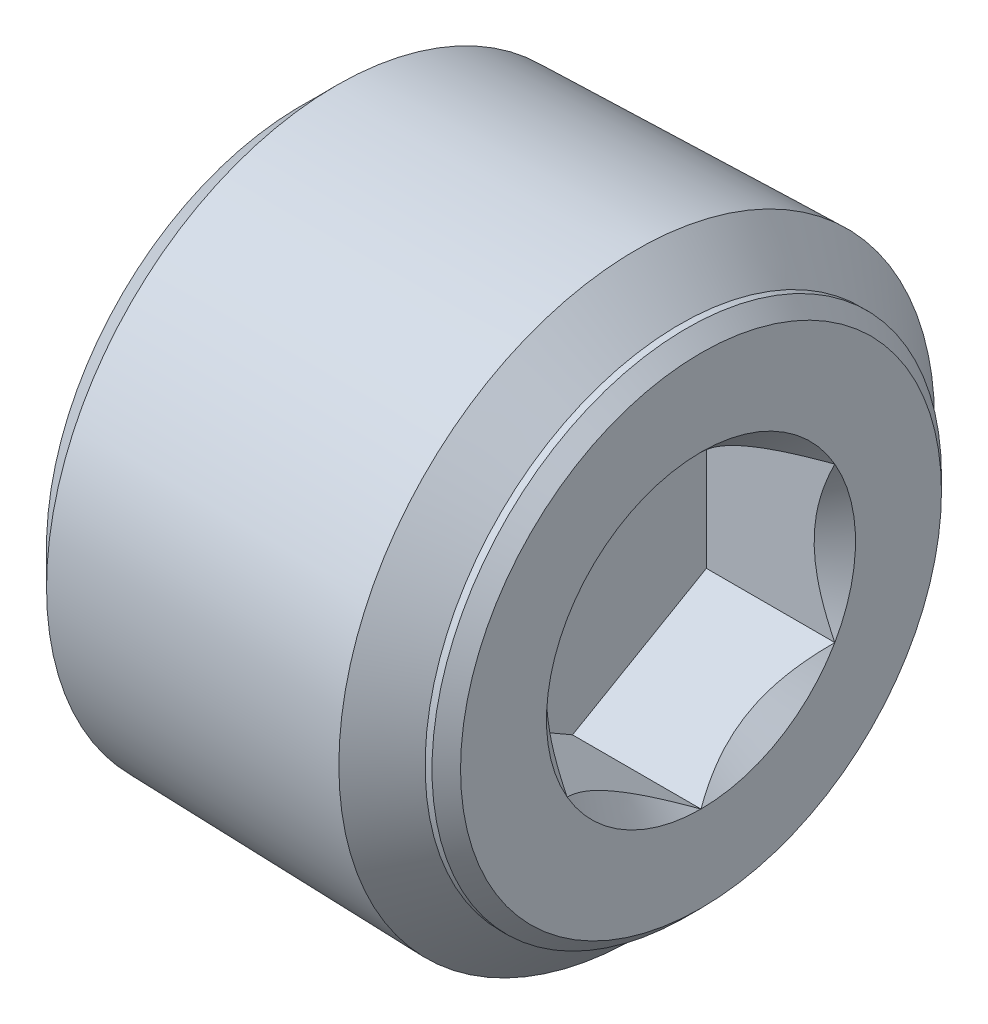
from build123d import *

# Parameters (mm, degrees)
SKETCH2_R          = 5.1435
EXTRUDE1_DEPTH     = 7.112
EXTRUDE1_TAPER     = -1.5
SKETCH5_OUTSIDE_W  = 32.218
SKETCH5_OUTSIDE_H  = 32.218
SKETCH5_OUTSIDE_R  = 4.532470965
CUT_EXTRUDE1_DEPTH = 8.1120001
CUT_EXTRUDE1_TAPER = 45
SKETCH9_OUTSIDE_W  = 15.994
SKETCH9_OUTSIDE_H  = 15.994
SKETCH9_OUTSIDE_R  = 4.532470965
CUT_EXTRUDE5_DEPTH = 0.376296296
SKETCH10_OUTSIDE_W = 31.44
SKETCH10_OUTSIDE_H = 31.44
SKETCH10_OUTSIDE_R = 4.532470965
CUT_EXTRUDE6_DEPTH = 7.735703804
CUT_EXTRUDE6_TAPER = 45
CUT_EXTRUDE7_DEPTH = 2.286
CHAMFER1_SIZE      = 0.254
SKETCH11_R         = 2.749630657
CUT_EXTRUDE8_DEPTH = 2.286
CUT_EXTRUDE8_TAPER = 45


with BuildPart() as part:
    # Sketch2 → Extrude1 (new body)
    with BuildSketch(Plane(origin=(-3.556, 0, 0), x_dir=(0, 0, -1), z_dir=(1, 0, 0))):
        Circle(SKETCH2_R)
    extrude(amount=EXTRUDE1_DEPTH, taper=EXTRUDE1_TAPER)

    # Sketch5 outside → Cut-Extrude1 (cut, through all)
    with BuildSketch(Plane(origin=(-3.556, 0, 0), x_dir=(0, 0, -1), z_dir=(1, 0, 0))):
        Rectangle(SKETCH5_OUTSIDE_W, SKETCH5_OUTSIDE_H)
        Circle(SKETCH5_OUTSIDE_R, mode=Mode.SUBTRACT)
    extrude(amount=CUT_EXTRUDE1_DEPTH, taper=CUT_EXTRUDE1_TAPER, mode=Mode.SUBTRACT)

    # Sketch9 outside → Cut-Extrude5 (cut)
    with BuildSketch(Plane(origin=(3.556, 0, 0), x_dir=(0, 0, -1), z_dir=(1, 0, 0))):
        Rectangle(SKETCH9_OUTSIDE_W, SKETCH9_OUTSIDE_H)
        Circle(SKETCH9_OUTSIDE_R, mode=Mode.SUBTRACT)
    extrude(amount=-CUT_EXTRUDE5_DEPTH, mode=Mode.SUBTRACT)

    # Sketch10 outside → Cut-Extrude6 (cut, through all)
    with BuildSketch(Plane(origin=(3.179703704, 0, 0), x_dir=(0, 0, -1), z_dir=(1, 0, 0))):
        Rectangle(SKETCH10_OUTSIDE_W, SKETCH10_OUTSIDE_H)
        Circle(SKETCH10_OUTSIDE_R, mode=Mode.SUBTRACT)
    extrude(amount=-CUT_EXTRUDE6_DEPTH, taper=CUT_EXTRUDE6_TAPER, mode=Mode.SUBTRACT)

    # Sketch6 → Cut-Extrude7 (cut)
    with BuildSketch(Plane(origin=(3.556, 0, 0), x_dir=(0, 0, -1), z_dir=(1, 0, 0))):
        Polygon((0, 2.749630657), (-2.38125, 1.374815329), (-2.38125, -1.374815329), (0, -2.749630657), (2.38125, -1.374815329), (2.38125, 1.374815329), align=None)
    extrude(amount=-CUT_EXTRUDE7_DEPTH, mode=Mode.SUBTRACT)

    # Chamfer1
    chamfer1_edges = [part.edges().sort_by_distance(p)[0] for p in [
        (3.556, 0, 4.532470965),
    ]]
    chamfer(chamfer1_edges, length=CHAMFER1_SIZE)

    # Sketch11 → Cut-Extrude8 (cut)
    with BuildSketch(Plane(origin=(3.556, 0, 0), x_dir=(0, 0, -1), z_dir=(1, 0, 0))):
        Circle(SKETCH11_R)
    extrude(amount=-CUT_EXTRUDE8_DEPTH, taper=CUT_EXTRUDE8_TAPER, mode=Mode.SUBTRACT)


solid = part.part
